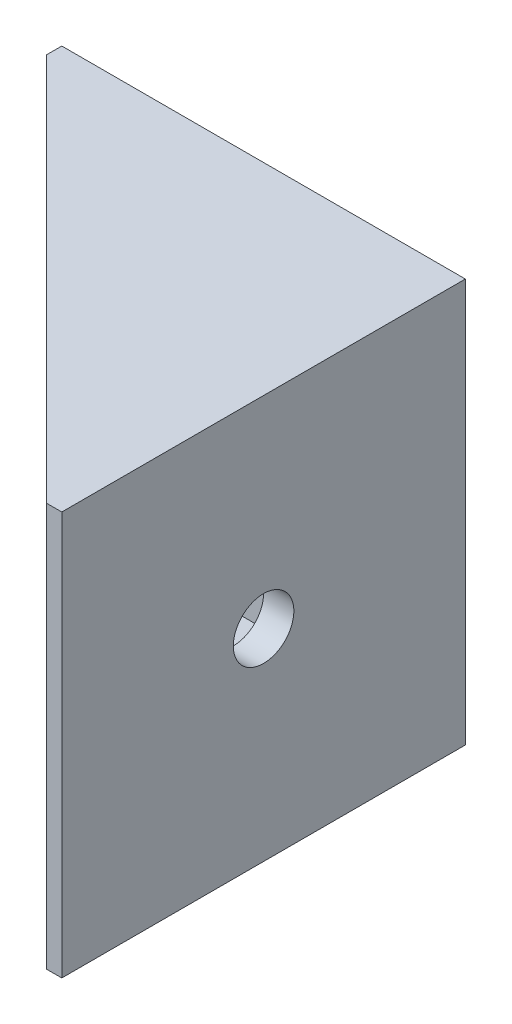
from build123d import *

# Parameters (mm, degrees)
BOSS_EXTRUDE1_DEPTH = 20
SKETCH3_R           = 3
CUT_EXTRUDE1_DEPTH  = 20
SKETCH4_R           = 3
CUT_EXTRUDE2_DEPTH  = 20
BOSS_EXTRUDE2_DEPTH = 3


with BuildPart() as part:
    # Sketch2 → Boss-Extrude1 (new body, symmetric)
    with BuildSketch(Plane(origin=(0, 0, 0), x_dir=(1, 0, 0), z_dir=(0, 1, 0))):
        Polygon((0, 0), (-40, 0), (-40, -1.5), (-38.5, -3), (-3, -3), (-3, -38.5), (-1.5, -40), (0, -40), align=None)
    extrude(amount=BOSS_EXTRUDE1_DEPTH, both=True)

    # Sketch3 → Cut-Extrude1 (cut, symmetric)
    with BuildSketch(Plane.XY.offset(3)):
        with Locations((-20, 0)):
            Circle(SKETCH3_R)
    extrude(amount=CUT_EXTRUDE1_DEPTH, both=True, mode=Mode.SUBTRACT)

    # Sketch4 → Cut-Extrude2 (cut, symmetric)
    with BuildSketch(Plane.ZY.offset(3)):
        with Locations((20, 0)):
            Circle(SKETCH4_R)
    extrude(amount=CUT_EXTRUDE2_DEPTH, both=True, mode=Mode.SUBTRACT)

    # Sketch5 → Boss-Extrude2 (add)
    with BuildSketch(Plane.XZ.offset(20)):
        Polygon((-38.5, 3), (-3, 38.5), (-3, 3), align=None)
    boss_extrude2 = extrude(amount=-BOSS_EXTRUDE2_DEPTH)

    # Mirror1: Boss-Extrude2 across plane
    add(boss_extrude2.mirror(Plane.ZX))


solid = part.part
